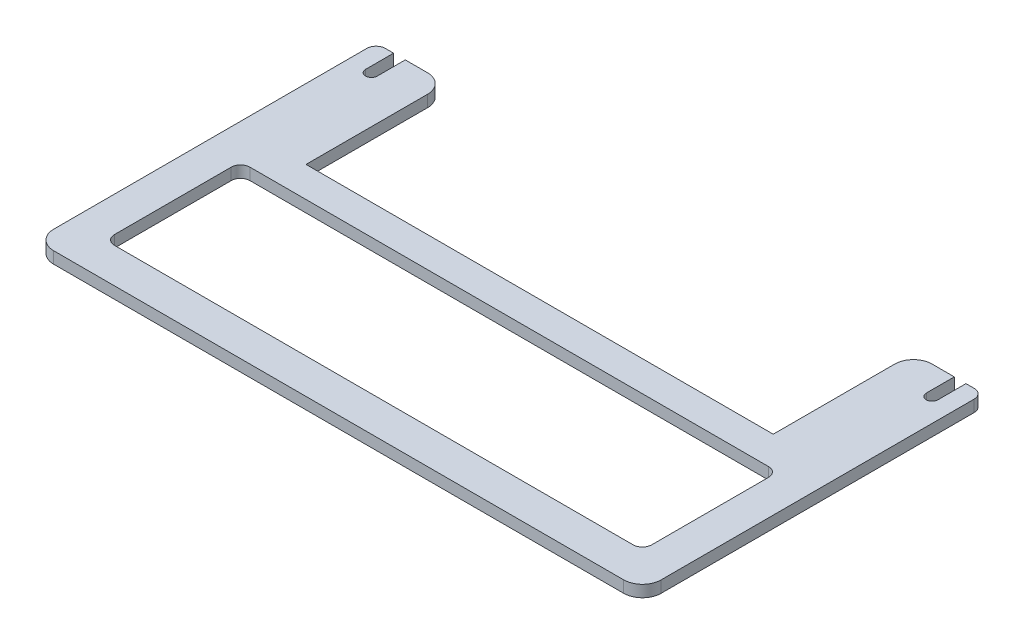
from build123d import *

# Parameters (mm, degrees)
SKETCH1_W           = 177.8
SKETCH1_H           = 67.31
BOSS_EXTRUDE1_DEPTH = 3.175
CUT_EXTRUDE2_DEPTH  = 4.175
SKETCH5_W           = 127
SKETCH5_H           = 12.7
CUT_EXTRUDE3_DEPTH  = 4.175
SKETCH7_W           = 25.4
SKETCH7_H           = 38.1
BOSS_EXTRUDE2_DEPTH = 3.175
CUT_EXTRUDE4_DEPTH  = 4.175
FILLET3_R           = 5.08
SKETCH9_W           = 6.35
SKETCH9_H           = 92.71
CUT_EXTRUDE5_DEPTH  = 4.175
FILLET4_R           = 2.54
FILLET5_R           = 5.08
SKETCH10_W          = 146.05
SKETCH10_H          = 36.83
CUT_EXTRUDE6_DEPTH  = 4.175
FILLET6_R           = 2.54


with BuildPart() as part:
    # Sketch1 → Boss-Extrude1 (new body)
    with BuildSketch(Plane(origin=(0, 0, 0), x_dir=(1, 0, 0), z_dir=(0, 1, 0))):
        with Locations((88.9, 33.655)):
            Rectangle(SKETCH1_W, SKETCH1_H)
    extrude(amount=BOSS_EXTRUDE1_DEPTH)

    # Sketch4 → Cut-Extrude2 (cut, through all)
    with BuildSketch(Plane(origin=(0, 3.175, 0), x_dir=(1, 0, 0), z_dir=(0, 1, 0))):
        with BuildLine():
            Line((11.1125, 67.31), (11.1125, 62.23))
            ThreePointArc((11.1125, 62.23), (12.7, 60.6425), (14.2875, 62.23))
            Line((14.2875, 62.23), (14.2875, 67.31))
            Line((14.2875, 67.31), (11.1125, 67.31))
        make_face()
        with BuildLine():
            Line((166.6875, 67.31), (166.6875, 62.23))
            ThreePointArc((166.6875, 62.23), (165.1, 60.6425), (163.5125, 62.23))
            Line((163.5125, 62.23), (163.5125, 67.31))
            Line((163.5125, 67.31), (166.6875, 67.31))
        make_face()
    extrude(amount=-CUT_EXTRUDE2_DEPTH, mode=Mode.SUBTRACT)

    # Sketch5 → Cut-Extrude3 (cut, through all)
    with BuildSketch(Plane(origin=(0, 3.175, 0), x_dir=(1, 0, 0), z_dir=(0, 1, 0))):
        with Locations((88.9, 60.96)):
            Rectangle(SKETCH5_W, SKETCH5_H)
    extrude(amount=-CUT_EXTRUDE3_DEPTH, mode=Mode.SUBTRACT)

    # Sketch7 → Boss-Extrude2 (add)
    with BuildSketch(Plane(origin=(0, 3.175, 0), x_dir=(1, 0, 0), z_dir=(0, 1, 0))):
        with Locations((12.7, 73.66)):
            Rectangle(SKETCH7_W, SKETCH7_H)
        with Locations((165.1, 73.66)):
            Rectangle(SKETCH7_W, SKETCH7_H)
    extrude(amount=-BOSS_EXTRUDE2_DEPTH)

    # Sketch8 → Cut-Extrude4 (cut, through all)
    with BuildSketch(Plane(origin=(0, 3.175, 0), x_dir=(1, 0, 0), z_dir=(0, 1, 0))):
        with BuildLine():
            Line((11.1125, 92.71), (11.1125, 85.09))
            ThreePointArc((11.1125, 85.09), (12.7, 83.5025), (14.2875, 85.09))
            Line((14.2875, 85.09), (14.2875, 92.71))
            Line((14.2875, 92.71), (11.1125, 92.71))
        make_face()
        with BuildLine():
            Line((163.5125, 85.09), (163.5125, 92.71))
            Line((163.5125, 92.71), (166.6875, 92.71))
            Line((166.6875, 92.71), (166.6875, 85.09))
            ThreePointArc((166.6875, 85.09), (165.1, 83.5025), (163.5125, 85.09))
        make_face()
    extrude(amount=-CUT_EXTRUDE4_DEPTH, mode=Mode.SUBTRACT)

    # Fillet3
    fillet3_edges = [part.edges().sort_by_distance(p)[0] for p in [
        (25.4, 1.5875, -92.71),
        (0, 1.5875, -92.71),
        (177.8, 1.5875, -92.71),
        (152.4, 1.5875, -92.71),
    ]]
    fillet(fillet3_edges, radius=FILLET3_R)

    # Sketch9 → Cut-Extrude5 (cut, through all)
    with BuildSketch(Plane(origin=(0, 3.175, 0), x_dir=(1, 0, 0), z_dir=(0, 1, 0))):
        with Locations((3.175, 46.355)):
            Rectangle(SKETCH9_W, SKETCH9_H)
        with Locations((174.625, 46.355)):
            Rectangle(SKETCH9_W, SKETCH9_H)
    extrude(amount=-CUT_EXTRUDE5_DEPTH, mode=Mode.SUBTRACT)

    # Fillet4
    fillet4_edges = [part.edges().sort_by_distance(p)[0] for p in [
        (6.35, 1.5875, -92.71),
        (171.45, 1.5875, -92.71),
    ]]
    fillet(fillet4_edges, radius=FILLET4_R)

    # Fillet5
    fillet5_edges = [part.edges().sort_by_distance(p)[0] for p in [
        (6.35, 1.5875, 0),
        (171.45, 1.5875, 0),
    ]]
    fillet(fillet5_edges, radius=FILLET5_R)

    # Sketch10 → Cut-Extrude6 (cut, through all)
    with BuildSketch(Plane(origin=(0, 3.175, 0), x_dir=(1, 0, 0), z_dir=(0, 1, 0))):
        with Locations((88.9, 27.94)):
            Rectangle(SKETCH10_W, SKETCH10_H)
    extrude(amount=-CUT_EXTRUDE6_DEPTH, mode=Mode.SUBTRACT)

    # Fillet6
    fillet6_edges = [part.edges().sort_by_distance(p)[0] for p in [
        (15.875, 1.5875, -9.525),
        (15.875, 1.5875, -46.355),
        (161.925, 1.5875, -46.355),
        (161.925, 1.5875, -9.525),
    ]]
    fillet(fillet6_edges, radius=FILLET6_R)


solid = part.part
